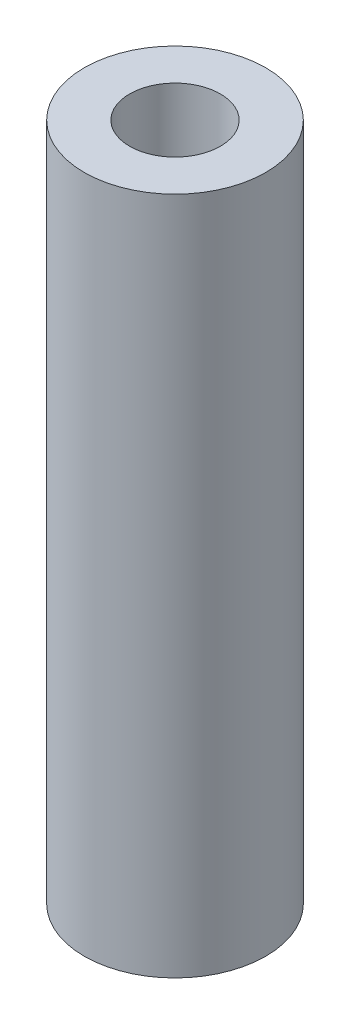
from build123d import *

# Parameters (mm, degrees)
SKETCH1_R           = 3.175
SKETCH1_R_2         = 1.5875
BOSS_EXTRUDE1_DEPTH = 23.75


with BuildPart() as part:
    # Sketch1 → Boss-Extrude1 (new body)
    with BuildSketch(Plane(origin=(0, 0, 0), x_dir=(1, 0, 0), z_dir=(0, 1, 0))):
        with Locations(Location((0, 0, 0), (0, 0, 270))):  # turned: the seam where the file's is
            Circle(SKETCH1_R)
        with Locations(Location((0, 0, 0), (0, 0, 270))):  # turned: the seam where the file's is
            Circle(SKETCH1_R_2, mode=Mode.SUBTRACT)
    extrude(amount=BOSS_EXTRUDE1_DEPTH)


solid = part.part
